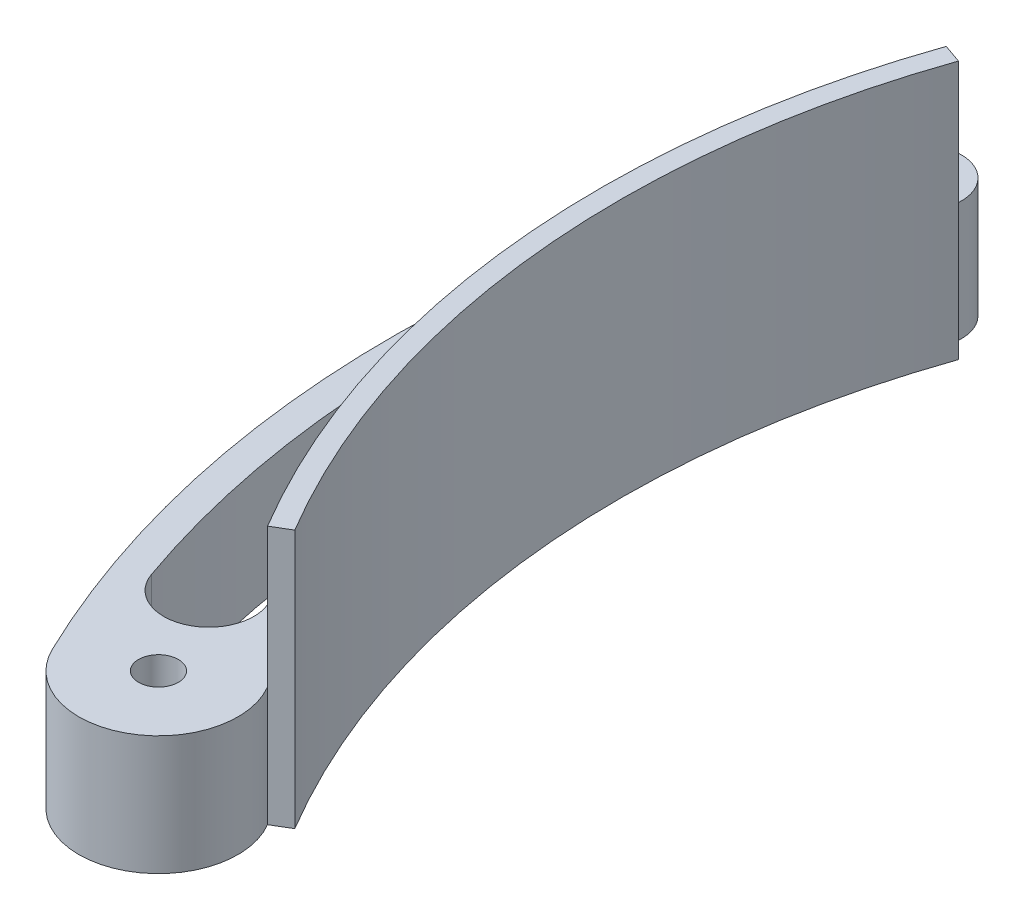
from build123d import *

# Parameters (mm, degrees)
SKETCH1_R           = 3.175
BOSS_EXTRUDE1_DEPTH = 19.05
CUT_EXTRUDE1_DEPTH  = 20.05
CUT_EXTRUDE2_DEPTH  = 20.05
BOSS_EXTRUDE2_DEPTH = 41.275


with BuildPart() as part:
    # Sketch1 → Boss-Extrude1 (new body)
    with BuildSketch(Plane(origin=(0, 0, 0), x_dir=(1, 0, 0), z_dir=(0, 1, 0))):
        with BuildLine():
            ThreePointArc((-135.252327308, 47.213234308), (-142.533412468, -14.370381558), (-123.105955958, -73.261211726))
            ThreePointArc((-123.105955958, -73.261211726), (-128.003817931, -90.940825055), (-145.454595651, -85.28148443))
            ThreePointArc((-145.454595651, -85.28148443), (-161.535072193, -16.847470136), (-147.026852029, 51.937030923))
            ThreePointArc((-147.026852029, 51.937030923), (-138.883189966, 55.199429393), (-135.252327308, 47.213234308))
        make_face()
        with Locations((-134.019604536, -79.756)):
            Circle(SKETCH1_R, mode=Mode.SUBTRACT)
        with Locations((-152.238831544, -5.766137402)):
            Circle(SKETCH1_R, mode=Mode.SUBTRACT)
    extrude(amount=BOSS_EXTRUDE1_DEPTH)

    # Sketch2 → Cut-Extrude1 (cut, through all)
    with BuildSketch(Plane(origin=(0, 19.05, 0), x_dir=(1, 0, 0), z_dir=(0, 1, 0))):
        with BuildLine():
            ThreePointArc((-143.414791125, 50.292648794), (-140.360917851, 51.51604822), (-138.999344354, 48.521225064))
            ThreePointArc((-138.999344354, 48.521225064), (-144.440688949, 28.495866167), (-147.012407175, 7.904375319))
            ThreePointArc((-147.012407175, 7.904375319), (-151.864331626, 3.75755277), (-155.768721686, 8.806616683))
            ThreePointArc((-155.768721686, 8.806616683), (-151.023065455, 29.975855535), (-143.414791125, 50.292648794))
        make_face()
    extrude(amount=-CUT_EXTRUDE1_DEPTH, mode=Mode.SUBTRACT)

    # Sketch4 → Cut-Extrude2 (cut, through all)
    with BuildSketch(Plane(origin=(0, 19.05, 0), x_dir=(1, 0, 0), z_dir=(0, 1, 0))):
        with BuildLine():
            ThreePointArc((-146.71076139, -19.632341547), (-142.203918186, -41.079459526), (-134.579739329, -61.626050533))
            ThreePointArc((-134.579739329, -61.626050533), (-138.426335153, -71.290308551), (-147.905040723, -67.006814278))
            ThreePointArc((-147.905040723, -67.006814278), (-154.06338729, -44.072990018), (-156.68753097, -20.472155339))
            ThreePointArc((-156.68753097, -20.472155339), (-152.098946776, -15.302721276), (-146.71076139, -19.632341547))
        make_face()
    extrude(amount=-CUT_EXTRUDE2_DEPTH, mode=Mode.SUBTRACT)


with BuildPart() as body_2:
    # Sketch3 → Boss-Extrude2 (new body)
    with BuildSketch(Plane(origin=(0, 0, 0), x_dir=(1, 0, 0), z_dir=(0, 1, 0))):
        with BuildLine():
            Line((-123.105955958, -73.261211726), (-120.377543814, -71.637514658))
            ThreePointArc((-120.377543814, -71.637514658), (-139.374427263, -14.051889059), (-132.254713671, 46.166841704))
            Line((-132.254713671, 46.166841704), (-135.252327308, 47.213234308))
            ThreePointArc((-135.252327308, 47.213234308), (-142.533412468, -14.370381558), (-123.105955958, -73.261211726))
        make_face()
    extrude(amount=BOSS_EXTRUDE2_DEPTH)


solid = Compound([part.part, body_2.part])
